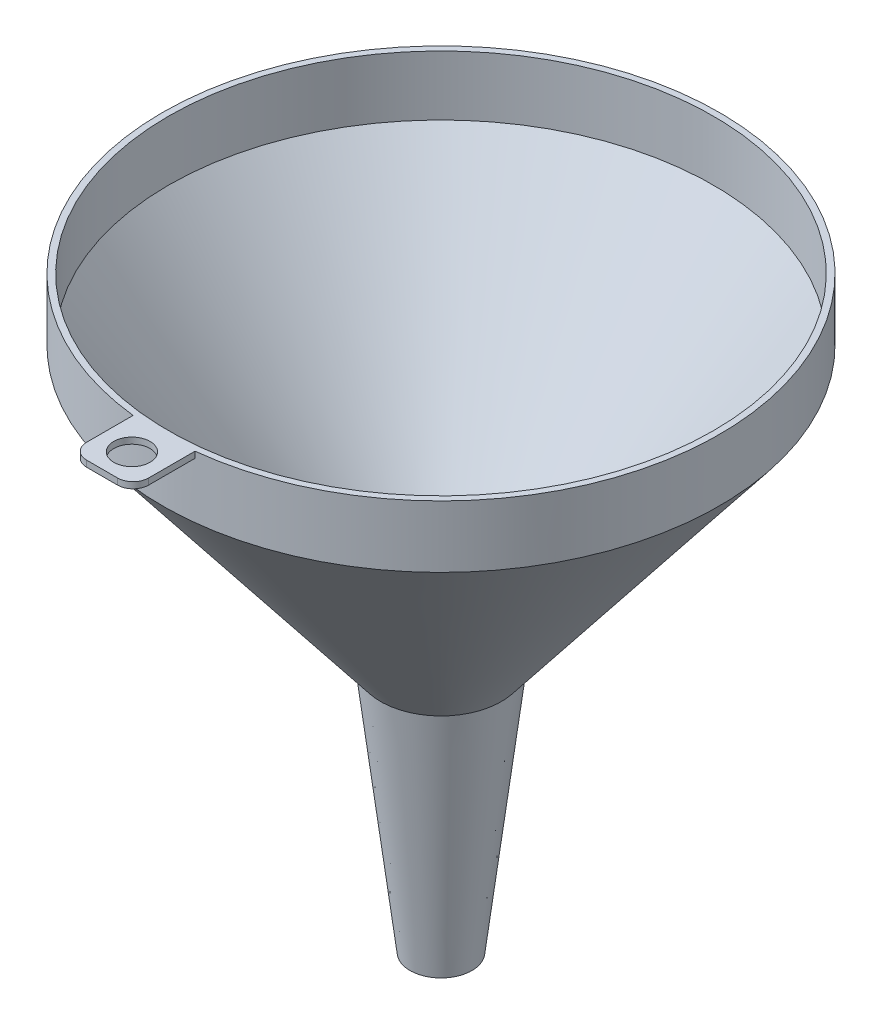
from build123d import *

# Parameters (mm, degrees)
VACIADO1_T              = -2
SALIENTE_EXTRUIR1_DEPTH = 2
CROQUIS3_R              = 5.855610057
CORTAR_EXTRUIR1_DEPTH   = 22
REDONDEO1_R             = 5


with BuildPart() as part:
    # Croquis1 → Revolución1 (revolve)
    with BuildSketch(Plane.XY, mode=Mode.PRIVATE) as revoluci_n1_sk:
        Polygon((0, 95), (0, -95), (10, -95), (19.509364421, -15), (90, 75), (90, 95), align=None)
    revolve(revoluci_n1_sk.sketch.rotate(Axis((0, 95, 0), (0, -1, 0)), 180), axis=Axis((0, 95, 0), (0, -1, 0)))

    # Vaciado1
    vaciado1_openings = [part.faces().sort_by_distance(p)[0] for p in [
        (0, -95, 0),
        (0, 95, 0),
    ]]
    offset(amount=VACIADO1_T, openings=vaciado1_openings, kind=Kind.INTERSECTION)

    # Croquis2 → Saliente-Extruir1 (add)
    with BuildSketch(Plane(origin=(0, 95, 0), x_dir=(1, 0, 0), z_dir=(0, 1, 0))):
        with BuildLine():
            Line((0, -109.4427191), (0, -90))
            ThreePointArc((0, -90), (-5.007758031, -89.860571774), (-10, -89.4427191))
            Line((-10, -89.4427191), (-10, -109.4427191))
            Line((-10, -109.4427191), (0, -109.4427191))
        make_face()
        with BuildLine():
            ThreePointArc((10, -89.4427191), (5.007758031, -89.860571774), (0, -90))
            Line((0, -90), (0, -109.4427191))
            Line((0, -109.4427191), (10, -109.4427191))
            Line((10, -109.4427191), (10, -89.4427191))
        make_face()
    extrude(amount=-SALIENTE_EXTRUIR1_DEPTH)

    # Croquis3 → Cortar-Extruir1 (cut)
    with BuildSketch(Plane(origin=(0, 95, 0), x_dir=(1, 0, 0), z_dir=(0, 1, 0))):
        with Locations(Location((0, -99.817771653, 0), (0, 0, 180))):
            Circle(CROQUIS3_R)
    extrude(amount=-CORTAR_EXTRUIR1_DEPTH, mode=Mode.SUBTRACT)

    # Redondeo1
    redondeo1_edges = [part.edges().sort_by_distance(p)[0] for p in [
        (10, 94, 109.4427191),
        (-10, 94, 109.4427191),
    ]]
    fillet(redondeo1_edges, radius=REDONDEO1_R)


solid = part.part
